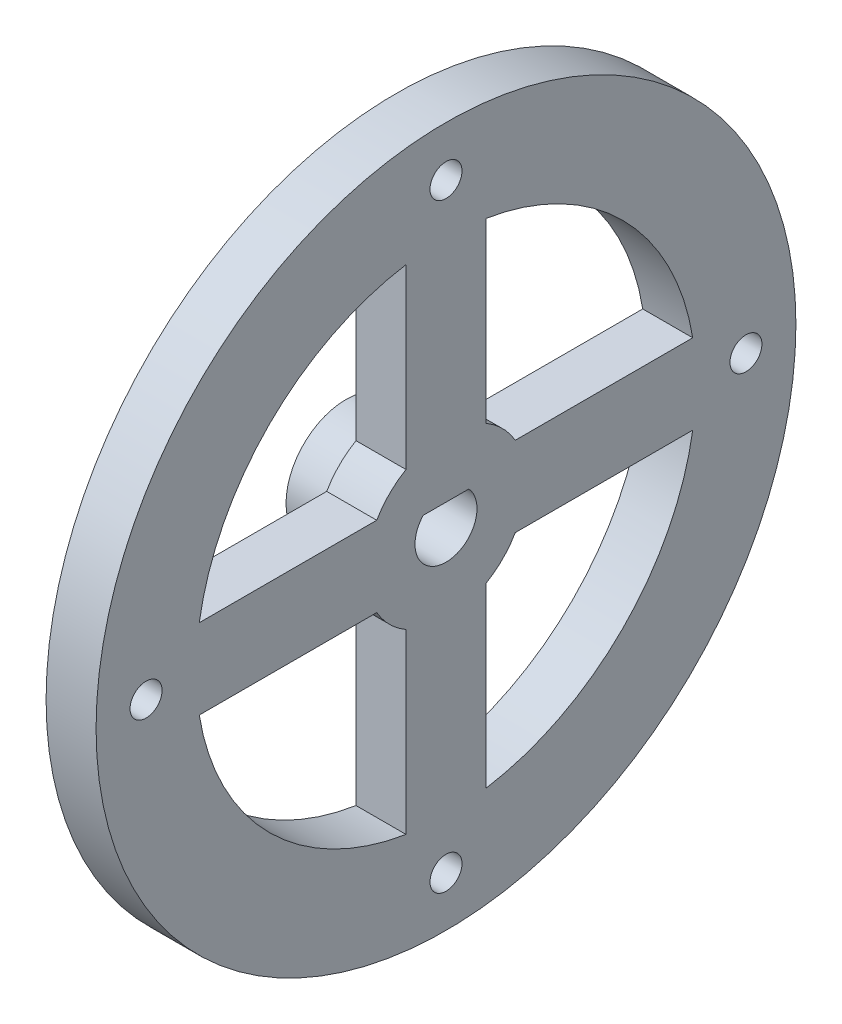
from build123d import *

# Parameters (mm, degrees)
SKETCH1_R           = 35
BOSS_EXTRUDE1_DEPTH = 5
SKETCH2_R           = 1.6
CUT_EXTRUDE1_DEPTH  = 6
SKETCH3_R           = 6
BOSS_EXTRUDE2_DEPTH = 5
SKETCH6_R           = 4
CUT_EXTRUDE2_DEPTH  = 2
CUT_EXTRUDE3_DEPTH  = 2.3876


with BuildPart() as part:
    # Sketch1 → Boss-Extrude1 (new body)
    with BuildSketch(Plane(origin=(0, 0, 0), x_dir=(0, 0, -1), z_dir=(1, 0, 0))):
        Circle(SKETCH1_R)
        with BuildLine():
            Line((4, 6.92820323), (4, 24.677925359))
            ThreePointArc((4, 24.677925359), (17.67766953, 17.67766953), (24.677925359, 4))
            Line((24.677925359, 4), (6.92820323, 4))
            ThreePointArc((6.92820323, 4), (5.656854249, 5.656854249), (4, 6.92820323))
        make_face(mode=Mode.SUBTRACT)
        with BuildLine():
            Line((-4, 24.677925359), (-4, 6.92820323))
            ThreePointArc((-4, 6.92820323), (-5.656854249, 5.656854249), (-6.92820323, 4))
            Line((-6.92820323, 4), (-24.677925359, 4))
            ThreePointArc((-24.677925359, 4), (-17.67766953, 17.67766953), (-4, 24.677925359))
        make_face(mode=Mode.SUBTRACT)
        with BuildLine():
            Line((-24.677925359, -4), (-6.92820323, -4))
            ThreePointArc((-6.92820323, -4), (-5.656854249, -5.656854249), (-4, -6.92820323))
            Line((-4, -6.92820323), (-4, -24.677925359))
            ThreePointArc((-4, -24.677925359), (-17.67766953, -17.67766953), (-24.677925359, -4))
        make_face(mode=Mode.SUBTRACT)
        with BuildLine():
            Line((4, -24.677925359), (4, -6.92820323))
            ThreePointArc((4, -6.92820323), (5.656854249, -5.656854249), (6.92820323, -4))
            Line((6.92820323, -4), (24.677925359, -4))
            ThreePointArc((24.677925359, -4), (17.67766953, -17.67766953), (4, -24.677925359))
        make_face(mode=Mode.SUBTRACT)
        with BuildLine():
            Line((2.28035085, 2.1), (-2.28035085, 2.1))
            ThreePointArc((-2.28035085, 2.1), (0, -3.1), (2.28035085, 2.1))
        make_face(mode=Mode.SUBTRACT)
    extrude(amount=BOSS_EXTRUDE1_DEPTH)

    # Sketch2 → Cut-Extrude1 (cut, through all)
    with BuildSketch(Plane.ZY):
        with Locations((0, 30)):
            Circle(SKETCH2_R)
        with Locations((30, 0)):
            Circle(SKETCH2_R)
        with Locations((0, -30)):
            Circle(SKETCH2_R)
        with Locations((-30, 0)):
            Circle(SKETCH2_R)
    extrude(amount=-CUT_EXTRUDE1_DEPTH, mode=Mode.SUBTRACT)

    # Sketch3 → Boss-Extrude2 (add)
    with BuildSketch(Plane.ZY):
        Circle(SKETCH3_R)
        with BuildLine():
            Line((-2.28035085, 2.1), (2.28035085, 2.1))
            ThreePointArc((2.28035085, 2.1), (0, -3.1), (-2.28035085, 2.1))
        make_face(mode=Mode.SUBTRACT)
    extrude(amount=BOSS_EXTRUDE2_DEPTH)

    # Sketch6 → Cut-Extrude2 (cut)
    with BuildSketch(Plane.ZY):
        with Locations((0, 30)):
            Circle(SKETCH6_R)
        with Locations((30, 0)):
            Circle(SKETCH6_R)
        with Locations((0, -30)):
            Circle(SKETCH6_R)
        with Locations((-30, 0)):
            Circle(SKETCH6_R)
    extrude(amount=-CUT_EXTRUDE2_DEPTH, mode=Mode.SUBTRACT)

    # Sketch7 → Cut-Extrude3 (cut)
    with BuildSketch(Plane.ZY.offset(5)):
        with BuildLine():
            Line((-3.9116, -3.300656457), (-3.9116, 3.300656457))
            ThreePointArc((-3.9116, 3.300656457), (0, 5.1181), (3.9116, 3.300656457))
            Line((3.9116, 3.300656457), (3.9116, -3.300656457))
            ThreePointArc((3.9116, -3.300656457), (0, -5.1181), (-3.9116, -3.300656457))
        make_face()
    extrude(amount=-CUT_EXTRUDE3_DEPTH, mode=Mode.SUBTRACT)


solid = part.part
